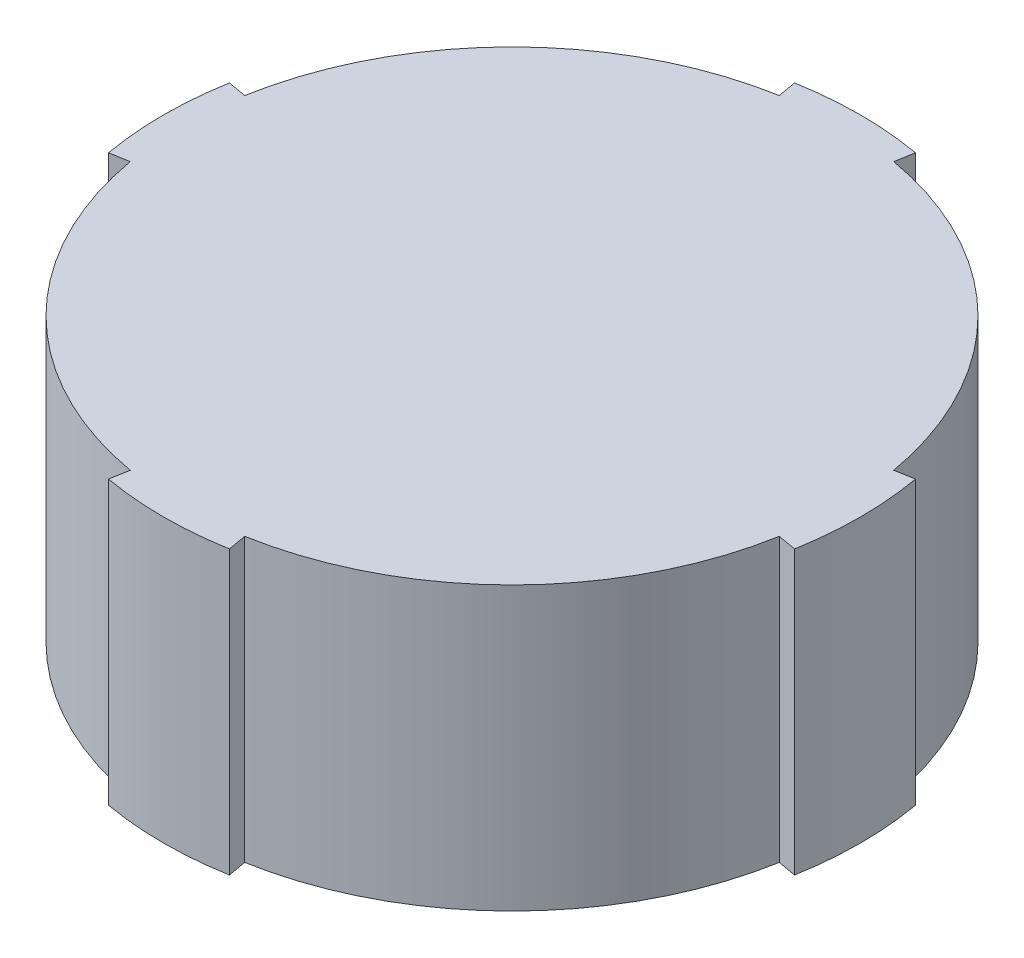
from build123d import *

# Parameters (mm, degrees)
SKETCH1_R           = 37
BOSS_EXTRUDE1_DEPTH = 30
CUT_EXTRUDE1_DEPTH  = 30


with BuildPart() as part:
    # Sketch1 → Boss-Extrude1 (new body)
    with BuildSketch(Plane(origin=(0, 0, 0), x_dir=(1, 0, 0), z_dir=(0, 1, 0))):
        Circle(SKETCH1_R)
    extrude(amount=BOSS_EXTRUDE1_DEPTH)

    # Sketch2 → Cut-Extrude1 (cut)
    with BuildSketch(Plane(origin=(0, 30, 0), x_dir=(1, 0, 0), z_dir=(0, 1, 0))):
        with BuildLine():
            Line((6.424982574, 36.437886861), (6.077686218, 34.468271355))
            ThreePointArc((6.077686218, 34.468271355), (24.748737342, 24.748737342), (34.468271355, 6.077686218))
            Line((34.468271355, 6.077686218), (36.437886861, 6.424982574))
            ThreePointArc((36.437886861, 6.424982574), (26.162950904, 26.162950904), (6.424982574, 36.437886861))
        make_face()
        with BuildLine():
            Line((36.437886861, -6.424982574), (34.468271355, -6.077686218))
            ThreePointArc((34.468271355, -6.077686218), (24.748737342, -24.748737342), (6.077686218, -34.468271355))
            Line((6.077686218, -34.468271355), (6.424982574, -36.437886861))
            ThreePointArc((6.424982574, -36.437886861), (26.162950904, -26.162950904), (36.437886861, -6.424982574))
        make_face()
        with BuildLine():
            Line((-6.424982574, -36.437886861), (-6.077686218, -34.468271355))
            ThreePointArc((-6.077686218, -34.468271355), (-24.748737342, -24.748737342), (-34.468271355, -6.077686218))
            Line((-34.468271355, -6.077686218), (-36.437886861, -6.424982574))
            ThreePointArc((-36.437886861, -6.424982574), (-26.162950904, -26.162950904), (-6.424982574, -36.437886861))
        make_face()
        with BuildLine():
            Line((-36.437886861, 6.424982574), (-34.468271355, 6.077686218))
            ThreePointArc((-34.468271355, 6.077686218), (-24.748737342, 24.748737342), (-6.077686218, 34.468271355))
            Line((-6.077686218, 34.468271355), (-6.424982574, 36.437886861))
            ThreePointArc((-6.424982574, 36.437886861), (-26.162950904, 26.162950904), (-36.437886861, 6.424982574))
        make_face()
    extrude(amount=-CUT_EXTRUDE1_DEPTH, mode=Mode.SUBTRACT)


solid = part.part
